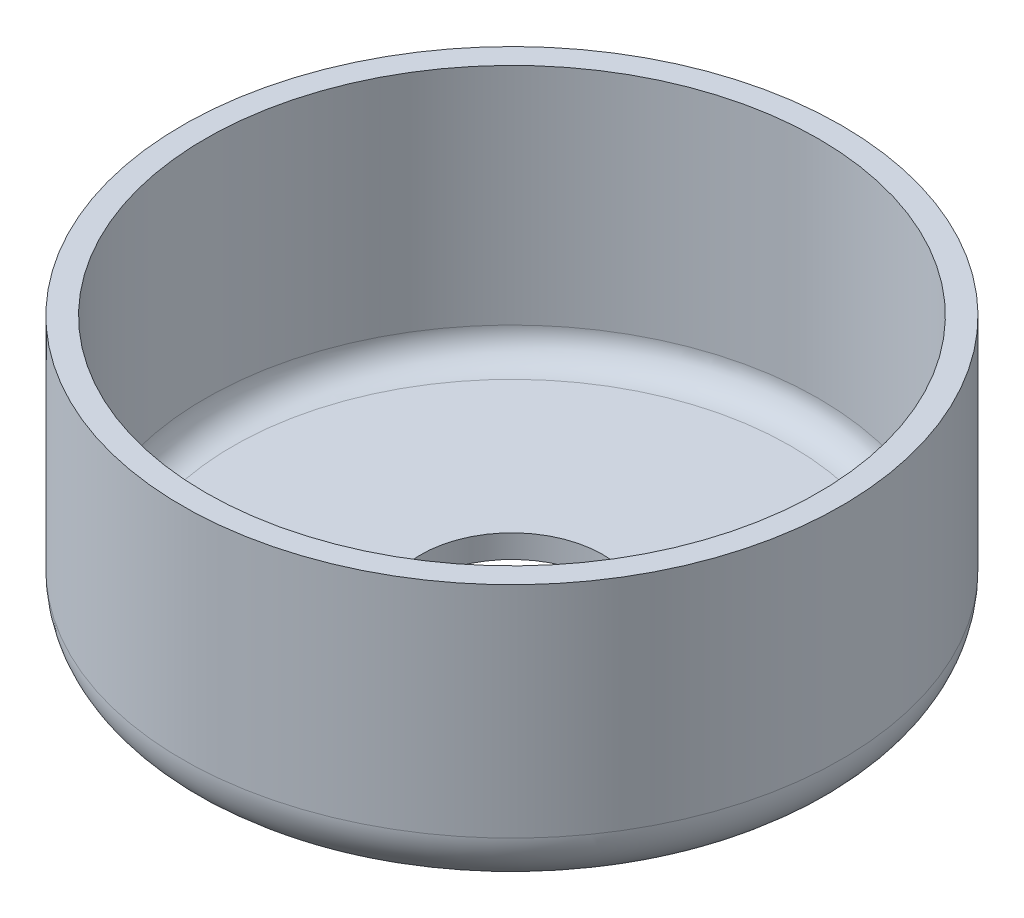
from build123d import *


with BuildPart() as part:
    # Sketch1 → Revolve1 (revolve)
    with BuildSketch(Plane.XY, mode=Mode.PRIVATE) as revolve1_sk:
        with BuildLine():
            Line((3.302, 0), (9.9314, 0))
            ThreePointArc((9.9314, 0), (11.368240979, 0.595159021), (11.9634, 2.032))
            Line((11.9634, 2.032), (11.9634, 10))
            Line((11.9634, 10), (11.1252, 10))
            Line((11.1252, 10), (11.1252, 1.8382))
            ThreePointArc((11.1252, 1.8382), (10.832306781, 1.131093219), (10.1252, 0.8382))
            Line((10.1252, 0.8382), (3.302, 0.8382))
            Line((3.302, 0.8382), (3.302, 0))
        make_face()
    revolve(revolve1_sk.sketch.rotate(Axis((0, 0, 0), (0, 1, 0)), 90), axis=Axis((0, 0, 0), (0, 1, 0)))  # turned: the seam where the file's is


solid = part.part
